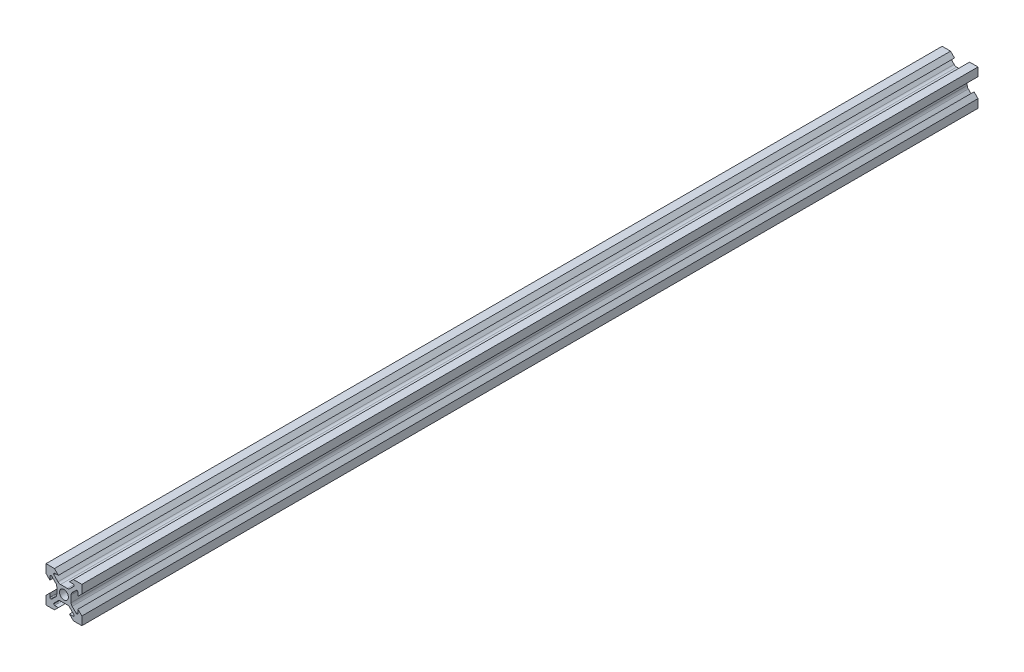
from build123d import *

# Parameters (mm, degrees)
SKETCH1_R           = 2.5
BOSS_EXTRUDE2_DEPTH = 500


with BuildPart() as part:
    # Sketch1 → Boss-Extrude2 (new body)
    with BuildSketch(Plane.XY):
        with BuildLine():
            Line((-4, 0), (-4, 1.898780669))
            ThreePointArc((-4, 1.898780669), (-4.152240935, 2.664147534), (-4.585786438, 3.312994231))
            Line((-4.585786438, 3.312994231), (-6.826345597, 5.553553391))
            ThreePointArc((-6.826345597, 5.553553391), (-6.988557271, 5.661939766), (-7.179898987, 5.7))
            Line((-7.179898987, 5.7), (-7.3, 5.7))
            ThreePointArc((-7.3, 5.7), (-7.653553391, 5.553553391), (-7.8, 5.2))
            Line((-7.8, 5.2), (-7.8, 3.1))
            Line((-7.8, 3.1), (-10, 5.3))
            Line((-10, 5.3), (-10, 10))
            Line((-10, 10), (-5.3, 10))
            Line((-5.3, 10), (-3.1, 7.8))
            Line((-3.1, 7.8), (-5.2, 7.8))
            ThreePointArc((-5.2, 7.8), (-5.553553391, 7.653553391), (-5.7, 7.3))
            Line((-5.7, 7.3), (-5.7, 7.179898987))
            ThreePointArc((-5.7, 7.179898987), (-5.661939766, 6.988557271), (-5.553553391, 6.826345597))
            Line((-5.553553391, 6.826345597), (-3.312994231, 4.585786438))
            ThreePointArc((-3.312994231, 4.585786438), (-2.664147534, 4.152240935), (-1.898780669, 4))
            Line((-1.898780669, 4), (0, 4))
            Line((0, 4), (1.898780669, 4))
            ThreePointArc((1.898780669, 4), (2.664147534, 4.152240935), (3.312994231, 4.585786438))
            Line((3.312994231, 4.585786438), (5.553553391, 6.826345597))
            ThreePointArc((5.553553391, 6.826345597), (5.661939766, 6.988557271), (5.7, 7.179898987))
            Line((5.7, 7.179898987), (5.7, 7.3))
            ThreePointArc((5.7, 7.3), (5.553553391, 7.653553391), (5.2, 7.8))
            Line((5.2, 7.8), (3.1, 7.8))
            Line((3.1, 7.8), (5.3, 10))
            Line((5.3, 10), (10, 10))
            Line((10, 10), (10, 5.3))
            Line((10, 5.3), (7.8, 3.1))
            Line((7.8, 3.1), (7.8, 5.2))
            ThreePointArc((7.8, 5.2), (7.653553391, 5.553553391), (7.3, 5.7))
            Line((7.3, 5.7), (7.179898987, 5.7))
            ThreePointArc((7.179898987, 5.7), (6.988557271, 5.661939766), (6.826345597, 5.553553391))
            Line((6.826345597, 5.553553391), (4.585786438, 3.312994231))
            ThreePointArc((4.585786438, 3.312994231), (4.152240935, 2.664147534), (4, 1.898780669))
            Line((4, 1.898780669), (4, 0))
            Line((4, 0), (4, -1.898780669))
            ThreePointArc((4, -1.898780669), (4.152240935, -2.664147534), (4.585786438, -3.312994231))
            Line((4.585786438, -3.312994231), (6.826345597, -5.553553391))
            ThreePointArc((6.826345597, -5.553553391), (6.988557271, -5.661939766), (7.179898987, -5.7))
            Line((7.179898987, -5.7), (7.3, -5.7))
            ThreePointArc((7.3, -5.7), (7.653553391, -5.553553391), (7.8, -5.2))
            Line((7.8, -5.2), (7.8, -3.1))
            Line((7.8, -3.1), (10, -5.3))
            Line((10, -5.3), (10, -10))
            Line((10, -10), (5.3, -10))
            Line((5.3, -10), (3.1, -7.8))
            Line((3.1, -7.8), (5.2, -7.8))
            ThreePointArc((5.2, -7.8), (5.553553391, -7.653553391), (5.7, -7.3))
            Line((5.7, -7.3), (5.7, -7.179898987))
            ThreePointArc((5.7, -7.179898987), (5.661939766, -6.988557271), (5.553553391, -6.826345597))
            Line((5.553553391, -6.826345597), (3.312994231, -4.585786438))
            ThreePointArc((3.312994231, -4.585786438), (2.664147534, -4.152240935), (1.898780669, -4))
            Line((1.898780669, -4), (0, -4))
            Line((0, -4), (-1.898780669, -4))
            ThreePointArc((-1.898780669, -4), (-2.664147534, -4.152240935), (-3.312994231, -4.585786438))
            Line((-3.312994231, -4.585786438), (-5.553553391, -6.826345597))
            ThreePointArc((-5.553553391, -6.826345597), (-5.661939766, -6.988557271), (-5.7, -7.179898987))
            Line((-5.7, -7.179898987), (-5.7, -7.3))
            ThreePointArc((-5.7, -7.3), (-5.553553391, -7.653553391), (-5.2, -7.8))
            Line((-5.2, -7.8), (-3.1, -7.8))
            Line((-3.1, -7.8), (-5.3, -10))
            Line((-5.3, -10), (-10, -10))
            Line((-10, -10), (-10, -5.3))
            Line((-10, -5.3), (-7.8, -3.1))
            Line((-7.8, -3.1), (-7.8, -5.2))
            ThreePointArc((-7.8, -5.2), (-7.653553391, -5.553553391), (-7.3, -5.7))
            Line((-7.3, -5.7), (-7.179898987, -5.7))
            ThreePointArc((-7.179898987, -5.7), (-6.988557271, -5.661939766), (-6.826345597, -5.553553391))
            Line((-6.826345597, -5.553553391), (-4.585786438, -3.312994231))
            ThreePointArc((-4.585786438, -3.312994231), (-4.152240935, -2.664147534), (-4, -1.898780669))
            Line((-4, -1.898780669), (-4, 0))
        make_face()
        Circle(SKETCH1_R, mode=Mode.SUBTRACT)
    extrude(amount=BOSS_EXTRUDE2_DEPTH)


solid = part.part
